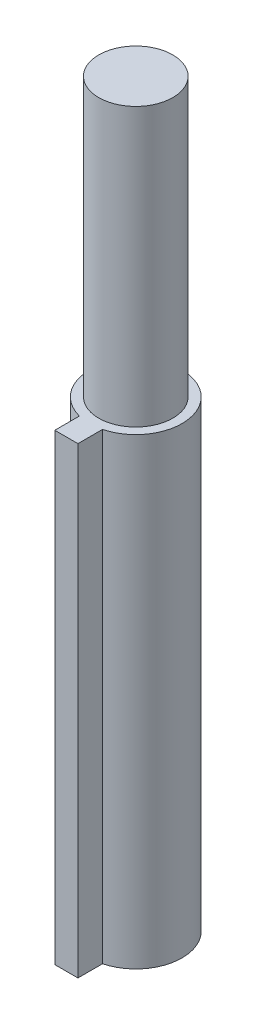
from build123d import *

# Parameters (mm, degrees)
SKETCH1_R           = 5
BOSS_EXTRUDE1_DEPTH = 50
SKETCH2_R           = 4
BOSS_EXTRUDE2_DEPTH = 30
SKETCH3_W           = 2.5
SKETCH3_H           = 5
BOSS_EXTRUDE3_DEPTH = 50


with BuildPart() as part:
    # Sketch1 → Boss-Extrude1 (new body)
    with BuildSketch(Plane(origin=(0, 0, 0), x_dir=(1, 0, 0), z_dir=(0, 1, 0))):
        Circle(SKETCH1_R)
    extrude(amount=BOSS_EXTRUDE1_DEPTH)

    # Sketch2 → Boss-Extrude2 (add)
    with BuildSketch(Plane(origin=(0, 50, 0), x_dir=(1, 0, 0), z_dir=(0, 1, 0))):
        Circle(SKETCH2_R)
    extrude(amount=BOSS_EXTRUDE2_DEPTH)

    # Sketch3 → Boss-Extrude3 (add)
    with BuildSketch(Plane.XZ):
        with Locations((0, 5)):
            Rectangle(SKETCH3_W, SKETCH3_H)
    extrude(amount=-BOSS_EXTRUDE3_DEPTH)


solid = part.part
